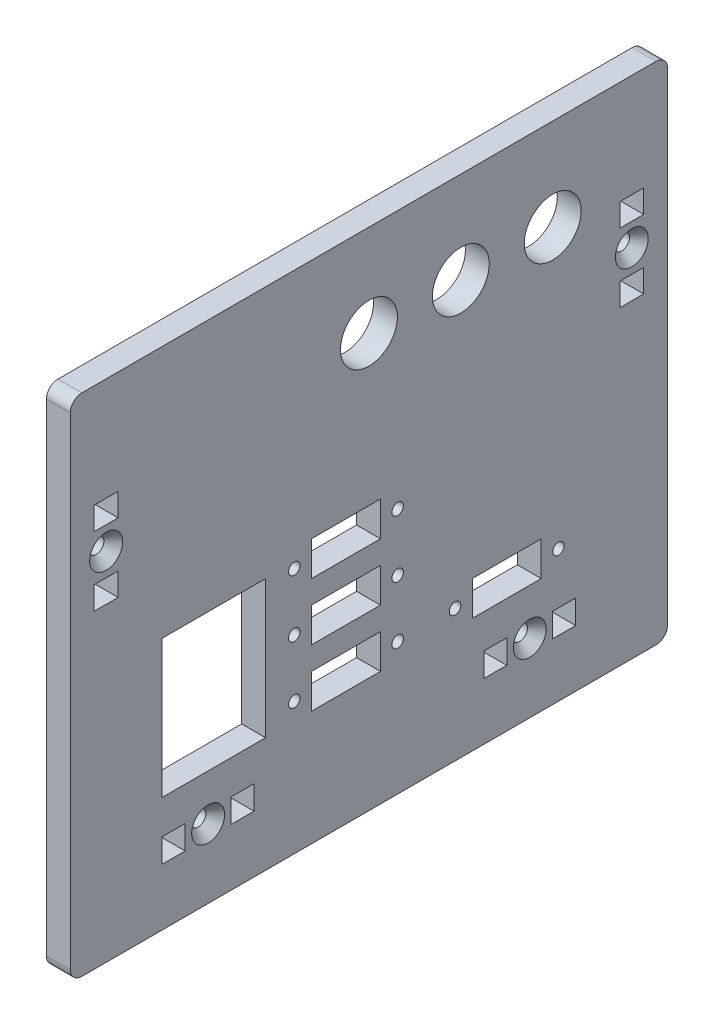
from build123d import *

# Parameters (mm, degrees)
SKETCH1_W                                         = 165.1
SKETCH1_H                                         = 139.7
BOSS_EXTRUDE1_DEPTH                               = 6.604
SKETCH2_R                                         = 7.874
SKETCH2_W                                         = 28.575
SKETCH2_H                                         = 38.1
CUT_EXTRUDE1_DEPTH                                = 7.604
SKETCH3_R                                         = 2.15265
SKETCH3_W                                         = 6.35
SKETCH3_H                                         = 6.604
CUT_EXTRUDE2_DEPTH                                = 7.604
SKETCH4_R                                         = 1.5875
SKETCH4_W                                         = 19.05
SKETCH4_H                                         = 9.525
CUT_EXTRUDE3_DEPTH                                = 7.604
LPATTERN1_COUNT                                   = 3
LPATTERN1_PITCH                                   = 15.875
FILLET1_R                                         = 3.175
SKETCH5_R                                         = 2.15265
SKETCH5_W                                         = 6.604
SKETCH5_H                                         = 6.35
CUT_EXTRUDE4_DEPTH                                = 7.604
CSK_FOR_8_FLAT_HEAD_SOCKET_CAP_SCREW1_D           = 4.3053
CSK_FOR_8_FLAT_HEAD_SOCKET_CAP_SCREW1_CSINK_D     = 9.1186
CSK_FOR_8_FLAT_HEAD_SOCKET_CAP_SCREW1_CSINK_ANGLE = 82
LPATTERN2_COUNT                                   = 2
LPATTERN2_PITCH                                   = 44.45


with BuildPart() as part:
    # Sketch1 → Boss-Extrude1 (new body)
    with BuildSketch(Plane(origin=(0, 0, 0), x_dir=(0, 0, -1), z_dir=(1, 0, 0))):
        Rectangle(SKETCH1_W, SKETCH1_H)
    extrude(amount=BOSS_EXTRUDE1_DEPTH)

    # Sketch2 → Cut-Extrude1 (cut, through all)
    with BuildSketch(Plane(origin=(6.604, 0, 0), x_dir=(0, 0, -1), z_dir=(1, 0, 0))):
        with Locations((50.8, 44.45)):
            Circle(SKETCH2_R)
        with Locations((25.4, 44.45)):
            Circle(SKETCH2_R)
        with Locations((0, 44.45)):
            Circle(SKETCH2_R)
        with Locations((-42.8625, -19.05)):
            Rectangle(SKETCH2_W, SKETCH2_H)
    extrude(amount=-CUT_EXTRUDE1_DEPTH, mode=Mode.SUBTRACT)

    # Sketch3 → Cut-Extrude2 (cut, through all)
    with BuildSketch(Plane(origin=(6.604, 0, 0), x_dir=(0, 0, -1), z_dir=(1, 0, 0))):
        with Locations((-44.45, -50.8)):
            Circle(SKETCH3_R)
        with Locations((44.45, -50.8)):
            Circle(SKETCH3_R)
        with Locations((-34.925, -50.8)):
            Rectangle(SKETCH3_W, SKETCH3_H)
        with Locations((-53.975, -50.8)):
            Rectangle(SKETCH3_W, SKETCH3_H)
        with Locations((53.975, -50.8)):
            Rectangle(SKETCH3_W, SKETCH3_H)
        with Locations((34.925, -50.8)):
            Rectangle(SKETCH3_W, SKETCH3_H)
    extrude(amount=-CUT_EXTRUDE2_DEPTH, mode=Mode.SUBTRACT)

    # Sketch4 → Cut-Extrude3 (cut, through all)
    with BuildSketch(Plane(origin=(6.604, 0, 0), x_dir=(0, 0, -1), z_dir=(1, 0, 0))):
        with Locations((-20.6375, -33.3375)):
            Circle(SKETCH4_R)
        with Locations((7.9375, -33.3375)):
            Circle(SKETCH4_R)
        with Locations((-6.35, -33.3375)):
            Rectangle(SKETCH4_W, SKETCH4_H)
    cut_extrude3 = extrude(amount=-CUT_EXTRUDE3_DEPTH, mode=Mode.SUBTRACT)

    # LPattern1: Cut-Extrude3 ×3
    with Locations(*[(0, i * LPATTERN1_PITCH, 0) for i in range(1, LPATTERN1_COUNT)]):
        add(cut_extrude3, mode=Mode.SUBTRACT)

    # Fillet1
    fillet1_edges = [part.edges().sort_by_distance(p)[0] for p in [
        (3.302, 69.85, 82.55),
        (3.302, 69.85, -82.55),
        (3.302, -69.85, -82.55),
        (3.302, -69.85, 82.55),
    ]]
    fillet(fillet1_edges, radius=FILLET1_R)

    # Sketch5 → Cut-Extrude4 (cut, through all)
    with BuildSketch(Plane(origin=(6.604, 0, 0), x_dir=(0, 0, -1), z_dir=(1, 0, 0))):
        with Locations((72.644, 28.575)):
            Circle(SKETCH5_R)
        with Locations((-72.644, 28.575)):
            Circle(SKETCH5_R)
        with Locations((72.644, 19.05)):
            Rectangle(SKETCH5_W, SKETCH5_H)
        with Locations((72.644, 38.1)):
            Rectangle(SKETCH5_W, SKETCH5_H)
        with Locations((-72.644, 38.1)):
            Rectangle(SKETCH5_W, SKETCH5_H)
        with Locations((-72.644, 19.05)):
            Rectangle(SKETCH5_W, SKETCH5_H)
    extrude(amount=-CUT_EXTRUDE4_DEPTH, mode=Mode.SUBTRACT)

    # CSK for #8 Flat Head Socket Cap Screw1 (through all)
    with Locations(Plane(origin=(6.604, 0, 0), x_dir=(0, 0, -1), z_dir=(1, 0, 0))):
        with Locations((-72.644, 28.575), (-44.45, -50.8), (44.45, -50.8), (72.644, 28.575)):
            CounterSinkHole(CSK_FOR_8_FLAT_HEAD_SOCKET_CAP_SCREW1_D / 2, CSK_FOR_8_FLAT_HEAD_SOCKET_CAP_SCREW1_CSINK_D / 2, counter_sink_angle=CSK_FOR_8_FLAT_HEAD_SOCKET_CAP_SCREW1_CSINK_ANGLE)

    # LPattern2: Cut-Extrude3 ×2
    with Locations(*[(0, 0, -i * LPATTERN2_PITCH) for i in range(1, LPATTERN2_COUNT)]):
        add(cut_extrude3, mode=Mode.SUBTRACT)


solid = part.part
